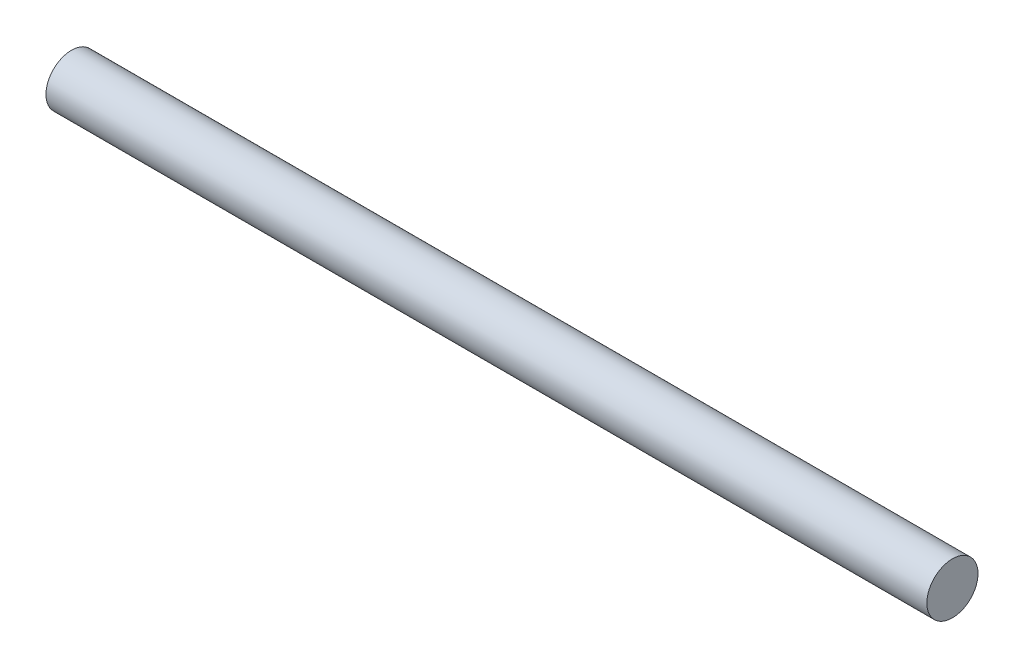
from build123d import *

# Parameters (mm, degrees)
ESQUISSE5_R        = 18
BOSS_EXTRU_3_DEPTH = 620


with BuildPart() as part:
    # Esquisse5 → Boss.-Extru.3 (new body)
    with BuildSketch(Plane(origin=(0, 0, 0), x_dir=(0, 0, -1), z_dir=(1, 0, 0))):
        Circle(ESQUISSE5_R)
    extrude(amount=BOSS_EXTRU_3_DEPTH)


solid = part.part
